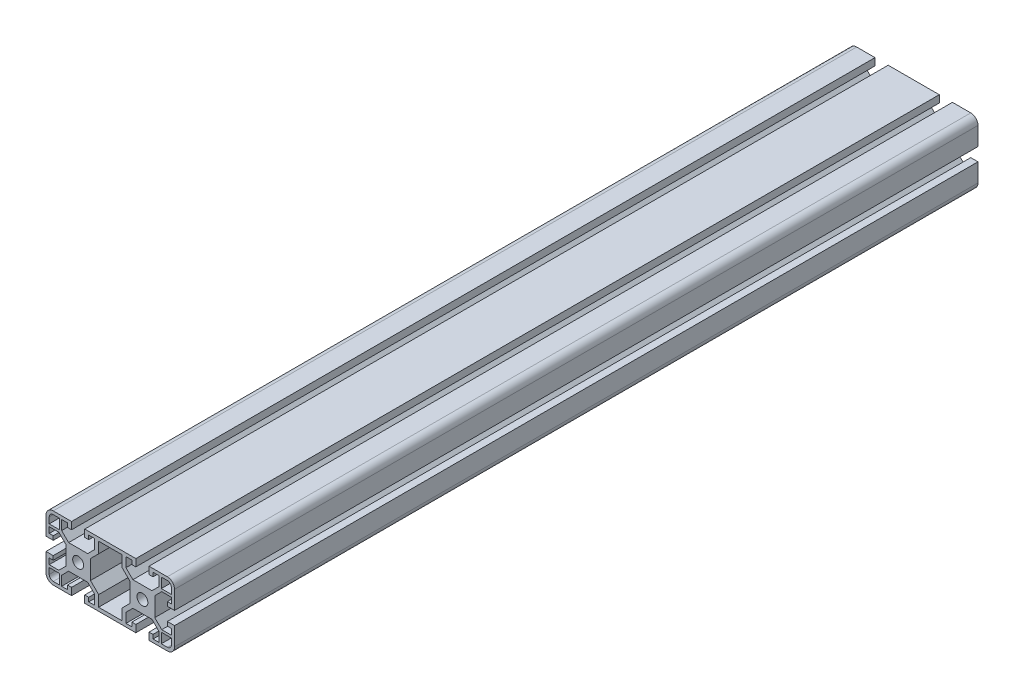
from build123d import *

# Parameters (mm, degrees)
SKETCH1_R           = 3.4
BOSS_EXTRUDE1_DEPTH = 500


with BuildPart() as part:
    # Sketch1 → Boss-Extrude1 (new body)
    with BuildSketch(Plane.XY):
        with BuildLine():
            Line((24.1, -20), (35.5, -20))
            ThreePointArc((35.5, -20), (38.681980515, -18.681980515), (40, -15.5))
            Line((40, -15.5), (40, -4.1))
            Line((40, -4.1), (35.5, -4.1))
            Line((35.5, -4.1), (35.5, -6.6))
            Line((35.5, -6.6), (38, -6.6))
            Line((38, -6.6), (38, -10.25))
            Line((38, -10.25), (32.017766953, -10.25))
            Line((32.017766953, -10.25), (27.7, -5.932233047))
            Line((27.7, -5.932233047), (27.7, 5.932233047))
            Line((27.7, 5.932233047), (32.017766953, 10.25))
            Line((32.017766953, 10.25), (38, 10.25))
            Line((38, 10.25), (38, 6.6))
            Line((38, 6.6), (35.5, 6.6))
            Line((35.5, 6.6), (35.5, 4.1))
            Line((35.5, 4.1), (40, 4.1))
            Line((40, 4.1), (40, 15.5))
            ThreePointArc((40, 15.5), (38.681980515, 18.681980515), (35.5, 20))
            Line((35.5, 20), (24.1, 20))
            Line((24.1, 20), (24.1, 15.5))
            Line((24.1, 15.5), (26.6, 15.5))
            Line((26.6, 15.5), (26.6, 18))
            Line((26.6, 18), (30.25, 18))
            Line((30.25, 18), (30.25, 12.017766953))
            Line((30.25, 12.017766953), (25.932233047, 7.7))
            Line((25.932233047, 7.7), (14.067766953, 7.7))
            Line((14.067766953, 7.7), (9.75, 12.017766953))
            Line((9.75, 12.017766953), (9.75, 18))
            Line((9.75, 18), (13.4, 18))
            Line((13.4, 18), (13.4, 15.5))
            Line((13.4, 15.5), (15.9, 15.5))
            Line((15.9, 15.5), (15.9, 20))
            Line((15.9, 20), (-15.9, 20))
            Line((-15.9, 20), (-15.9, 15.5))
            Line((-15.9, 15.5), (-13.4, 15.5))
            Line((-13.4, 15.5), (-13.4, 18))
            Line((-13.4, 18), (-9.75, 18))
            Line((-9.75, 18), (-9.75, 12.017766953))
            Line((-9.75, 12.017766953), (-14.067766953, 7.7))
            Line((-14.067766953, 7.7), (-25.932233047, 7.7))
            Line((-25.932233047, 7.7), (-30.25, 12.017766953))
            Line((-30.25, 12.017766953), (-30.25, 18))
            Line((-30.25, 18), (-26.6, 18))
            Line((-26.6, 18), (-26.6, 15.5))
            Line((-26.6, 15.5), (-24.1, 15.5))
            Line((-24.1, 15.5), (-24.1, 20))
            Line((-24.1, 20), (-35.5, 20))
            ThreePointArc((-35.5, 20), (-38.681980515, 18.681980515), (-40, 15.5))
            Line((-40, 15.5), (-40, 4.1))
            Line((-40, 4.1), (-35.5, 4.1))
            Line((-35.5, 4.1), (-35.5, 6.6))
            Line((-35.5, 6.6), (-38, 6.6))
            Line((-38, 6.6), (-38, 10.25))
            Line((-38, 10.25), (-32.017766953, 10.25))
            Line((-32.017766953, 10.25), (-27.7, 5.932233047))
            Line((-27.7, 5.932233047), (-27.7, -5.932233047))
            Line((-27.7, -5.932233047), (-32.017766953, -10.25))
            Line((-32.017766953, -10.25), (-38, -10.25))
            Line((-38, -10.25), (-38, -6.6))
            Line((-38, -6.6), (-35.5, -6.6))
            Line((-35.5, -6.6), (-35.5, -4.1))
            Line((-35.5, -4.1), (-40, -4.1))
            Line((-40, -4.1), (-40, -15.5))
            ThreePointArc((-40, -15.5), (-38.681980515, -18.681980515), (-35.5, -20))
            Line((-35.5, -20), (-24.1, -20))
            Line((-24.1, -20), (-24.1, -15.5))
            Line((-24.1, -15.5), (-26.6, -15.5))
            Line((-26.6, -15.5), (-26.6, -18))
            Line((-26.6, -18), (-30.25, -18))
            Line((-30.25, -18), (-30.25, -12.017766953))
            Line((-30.25, -12.017766953), (-25.932233047, -7.7))
            Line((-25.932233047, -7.7), (-14.067766953, -7.7))
            Line((-14.067766953, -7.7), (-9.75, -12.017766953))
            Line((-9.75, -12.017766953), (-9.75, -18))
            Line((-9.75, -18), (-13.4, -18))
            Line((-13.4, -18), (-13.4, -15.5))
            Line((-13.4, -15.5), (-15.9, -15.5))
            Line((-15.9, -15.5), (-15.9, -20))
            Line((-15.9, -20), (15.9, -20))
            Line((15.9, -20), (15.9, -15.5))
            Line((15.9, -15.5), (13.4, -15.5))
            Line((13.4, -15.5), (13.4, -18))
            Line((13.4, -18), (9.75, -18))
            Line((9.75, -18), (9.75, -12.017766953))
            Line((9.75, -12.017766953), (14.067766953, -7.7))
            Line((14.067766953, -7.7), (25.932233047, -7.7))
            Line((25.932233047, -7.7), (30.25, -12.017766953))
            Line((30.25, -12.017766953), (30.25, -18))
            Line((30.25, -18), (26.6, -18))
            Line((26.6, -18), (26.6, -15.5))
            Line((26.6, -15.5), (24.1, -15.5))
            Line((24.1, -15.5), (24.1, -20))
        make_face()
        with Locations((-20, 0)):
            Circle(SKETCH1_R, mode=Mode.SUBTRACT)
        with Locations((20, 0)):
            Circle(SKETCH1_R, mode=Mode.SUBTRACT)
        with BuildLine():
            Line((38, -15.5), (38, -11.75))
            Line((38, -11.75), (31.75, -11.75))
            Line((31.75, -11.75), (31.75, -18))
            Line((31.75, -18), (35.5, -18))
            ThreePointArc((35.5, -18), (37.267766953, -17.267766953), (38, -15.5))
        make_face(mode=Mode.SUBTRACT)
        with BuildLine():
            Line((-38, 15.5), (-38, 11.75))
            Line((-38, 11.75), (-31.75, 11.75))
            Line((-31.75, 11.75), (-31.75, 18))
            Line((-31.75, 18), (-35.5, 18))
            ThreePointArc((-35.5, 18), (-37.267766953, 17.267766953), (-38, 15.5))
        make_face(mode=Mode.SUBTRACT)
        Polygon((-7.25, -10.982233047), (-7.25, -17.8), (7.25, -17.8), (7.25, -10.982233047), (12.3, -5.932233047), (12.3, 5.932233047), (7.25, 10.982233047), (7.25, 17.8), (-7.25, 17.8), (-7.25, 10.982233047), (-12.3, 5.932233047), (-12.3, -5.932233047), align=None, mode=Mode.SUBTRACT)
        with BuildLine():
            Line((-35.5, -18), (-31.75, -18))
            Line((-31.75, -18), (-31.75, -11.75))
            Line((-31.75, -11.75), (-38, -11.75))
            Line((-38, -11.75), (-38, -15.5))
            ThreePointArc((-38, -15.5), (-37.267766953, -17.267766953), (-35.5, -18))
        make_face(mode=Mode.SUBTRACT)
        with BuildLine():
            Line((35.5, 18), (31.75, 18))
            Line((31.75, 18), (31.75, 11.75))
            Line((31.75, 11.75), (38, 11.75))
            Line((38, 11.75), (38, 15.5))
            ThreePointArc((38, 15.5), (37.267766953, 17.267766953), (35.5, 18))
        make_face(mode=Mode.SUBTRACT)
    extrude(amount=BOSS_EXTRUDE1_DEPTH)


solid = part.part
